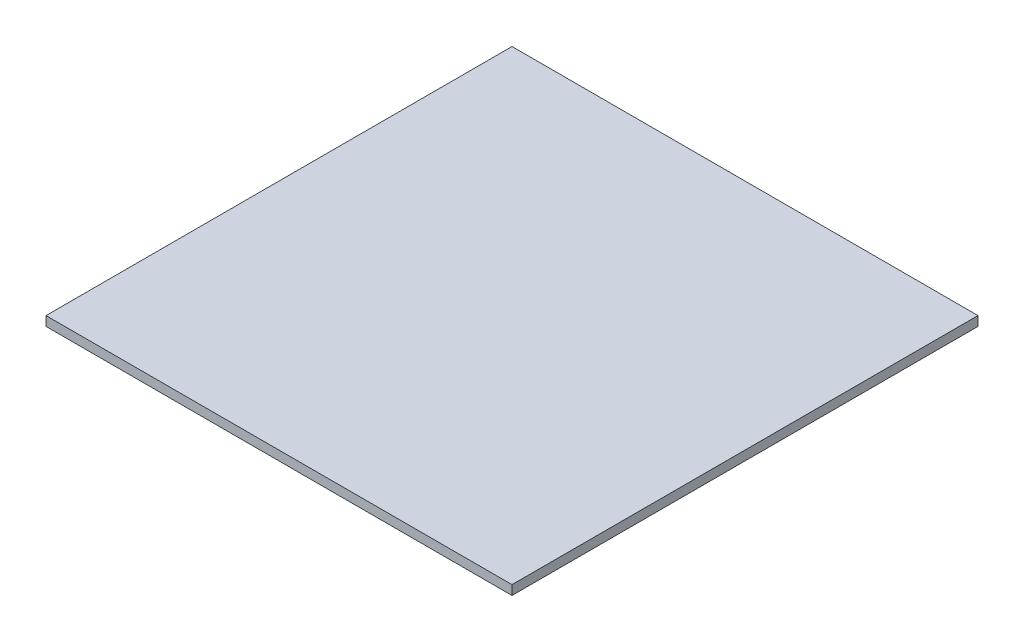
from build123d import *

# Parameters (mm, degrees)
SKETCH2_W           = 989.943395056
SKETCH2_H           = 990
BOSS_EXTRUDE1_DEPTH = 20


with BuildPart() as part:
    # Sketch2 → Boss-Extrude1 (new body)
    with BuildSketch(Plane(origin=(0, 695.2, 0), x_dir=(1, 0, 0), z_dir=(0, 1, 0))):
        with Locations((599.521516334, 0.396752623)):
            Rectangle(SKETCH2_W, SKETCH2_H)
    extrude(amount=BOSS_EXTRUDE1_DEPTH)


solid = part.part
